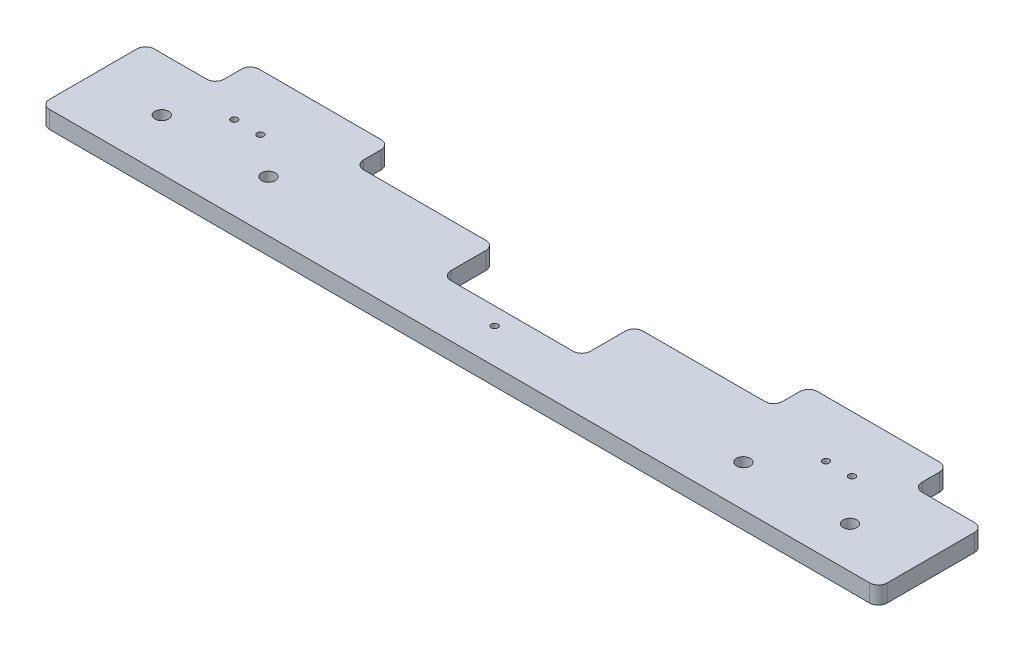
from build123d import *

# Parameters (mm, degrees)
SKETCH1_W           = 304.8
SKETCH1_H           = 38.1
BOSS_EXTRUDE1_DEPTH = 6.35
SKETCH5_W           = 50.8
SKETCH5_H           = 12.7
BOSS_EXTRUDE2_DEPTH = 6.35
FILLET1_R           = 3.175
FILLET2_R           = 3.175
SKETCH2_R           = 1.4732
CUT_EXTRUDE1_DEPTH  = 6.35
SKETCH3_R           = 1.2
CUT_EXTRUDE2_DEPTH  = 6.35
SKETCH4_R           = 2.4765
CUT_EXTRUDE3_DEPTH  = 6.35
SKETCH6_W           = 50.8
SKETCH6_H           = 19.05
CUT_EXTRUDE4_DEPTH  = 6.35
FILLET3_R           = 3.175
SKETCH7_R           = 1.2192
CUT_EXTRUDE5_DEPTH  = 6.35


with BuildPart() as part:
    # Sketch1 → Boss-Extrude1 (new body)
    with BuildSketch(Plane(origin=(0, 0, 0), x_dir=(1, 0, 0), z_dir=(0, 1, 0))):
        Rectangle(SKETCH1_W, SKETCH1_H)
    extrude(amount=BOSS_EXTRUDE1_DEPTH)

    # Sketch5 → Boss-Extrude2 (add)
    with BuildSketch(Plane(origin=(0, 6.35, 0), x_dir=(1, 0, 0), z_dir=(0, 1, 0))):
        with Locations((-101.6, 25.4)):
            Rectangle(SKETCH5_W, SKETCH5_H)
        with Locations((101.6, 25.4)):
            Rectangle(SKETCH5_W, SKETCH5_H)
    extrude(amount=-BOSS_EXTRUDE2_DEPTH)

    # Fillet1
    fillet1_edges = [part.edges().sort_by_distance(p)[0] for p in [
        (127, 3.175, -19.05),
        (127, 3.175, -31.75),
        (76.2, 3.175, -31.75),
        (76.2, 3.175, -19.05),
        (-76.2, 3.175, -19.05),
        (-76.2, 3.175, -31.75),
        (-127, 3.175, -31.75),
        (-127, 3.175, -19.05),
    ]]
    fillet(fillet1_edges, radius=FILLET1_R)

    # Fillet2
    fillet2_edges = [part.edges().sort_by_distance(p)[0] for p in [
        (152.4, 3.175, -19.05),
        (152.4, 3.175, 19.05),
        (-152.4, 3.175, 19.05),
        (-152.4, 3.175, -19.05),
    ]]
    fillet(fillet2_edges, radius=FILLET2_R)

    # Sketch2 → Cut-Extrude1 (cut)
    with BuildSketch(Plane(origin=(0, 6.35, 0), x_dir=(1, 0, 0), z_dir=(0, 1, 0))):
        with Locations((0, 12.7)):
            Circle(SKETCH2_R)
    extrude(amount=-CUT_EXTRUDE1_DEPTH, mode=Mode.SUBTRACT)

    # Sketch3 → Cut-Extrude2 (cut)
    with BuildSketch(Plane(origin=(0, 6.35, 0), x_dir=(1, 0, 0), z_dir=(0, 1, 0))):
        with Locations((-112.4, 11.35)):
            Circle(SKETCH3_R)
        with Locations((-102.9, 11.35)):
            Circle(SKETCH3_R)
    cut_extrude2 = extrude(amount=-CUT_EXTRUDE2_DEPTH, mode=Mode.SUBTRACT)

    # Mirror1: Cut-Extrude2 across plane
    add(cut_extrude2.mirror(Plane(origin=(0, 0, 0), x_dir=(0, 0, 1), z_dir=(1, 0, 0))), mode=Mode.SUBTRACT)

    # Sketch4 → Cut-Extrude3 (cut)
    with BuildSketch(Plane(origin=(0, 6.35, 0), x_dir=(1, 0, 0), z_dir=(0, 1, 0))):
        with Locations((-127, -0.457547173)):
            Circle(SKETCH4_R)
        with Locations((-88.2, -0.457547173)):
            Circle(SKETCH4_R)
        with Locations((88.2, -4.001229652)):
            Circle(SKETCH4_R)
        with Locations((127, -4.001229652)):
            Circle(SKETCH4_R)
    extrude(amount=-CUT_EXTRUDE3_DEPTH, mode=Mode.SUBTRACT)

    # Sketch6 → Cut-Extrude4 (cut)
    with BuildSketch(Plane(origin=(0, 6.35, 0), x_dir=(1, 0, 0), z_dir=(0, 1, 0))):
        with Locations((0, 9.525)):
            Rectangle(SKETCH6_W, SKETCH6_H)
    extrude(amount=-CUT_EXTRUDE4_DEPTH, mode=Mode.SUBTRACT)

    # Fillet3
    fillet3_edges = [part.edges().sort_by_distance(p)[0] for p in [
        (25.4, 3.175, -19.05),
        (25.4, 3.175, 0),
        (-25.4, 3.175, 0),
        (-25.4, 3.175, -19.05),
    ]]
    fillet(fillet3_edges, radius=FILLET3_R)

    # Sketch7 → Cut-Extrude5 (cut)
    with BuildSketch(Plane(origin=(0, 6.35, 0), x_dir=(1, 0, 0), z_dir=(0, 1, 0))):
        with Locations((0, -6.35)):
            Circle(SKETCH7_R)
    extrude(amount=-CUT_EXTRUDE5_DEPTH, mode=Mode.SUBTRACT)


solid = part.part
